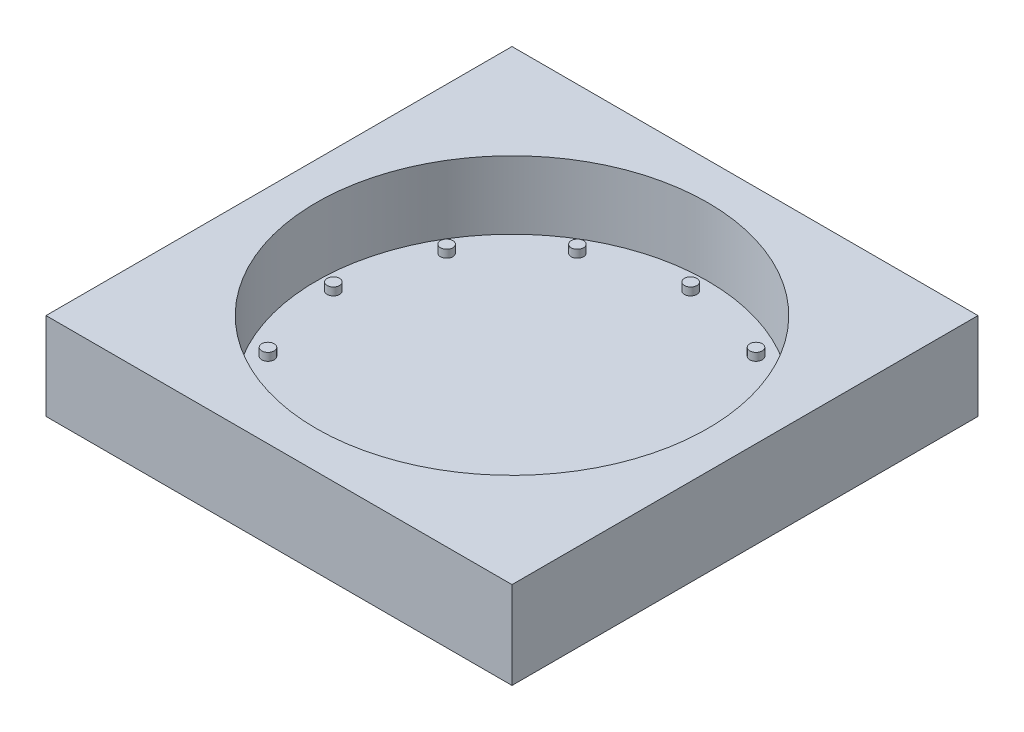
from build123d import *

# Parameters (mm, degrees)
SKETCH1_W           = 152.4
SKETCH1_H           = 152.4
SKETCH1_R           = 64.008
BOSS_EXTRUDE1_DEPTH = 22.225
SKETCH2_W           = 152.4
SKETCH2_H           = 152.4
BOSS_EXTRUDE2_DEPTH = 6.35
SKETCH3_R           = 2.032
BOSS_EXTRUDE3_DEPTH = 2.54
CIRPATTERN1_COUNT   = 12


with BuildPart() as part:
    # Sketch1 → Boss-Extrude1 (new body)
    with BuildSketch(Plane(origin=(0, 0, 0), x_dir=(1, 0, 0), z_dir=(0, 1, 0))):
        Rectangle(SKETCH1_W, SKETCH1_H)
        Circle(SKETCH1_R, mode=Mode.SUBTRACT)
    extrude(amount=BOSS_EXTRUDE1_DEPTH)

    # Sketch2 → Boss-Extrude2 (add)
    with BuildSketch(Plane(origin=(0, 0, 0), x_dir=(-1, 0, 0), z_dir=(0, -1, 0))):
        Rectangle(SKETCH2_W, SKETCH2_H)
    extrude(amount=BOSS_EXTRUDE2_DEPTH)

    # Sketch3 → Boss-Extrude3 (add)
    with BuildSketch(Plane(origin=(0, 0, 0), x_dir=(1, 0, 0), z_dir=(0, 1, 0))):
        with Locations((-58.42, 0)):
            Circle(SKETCH3_R)
    boss_extrude3 = extrude(amount=BOSS_EXTRUDE3_DEPTH)

    # CirPattern1: Boss-Extrude3 ×12 about axis
    cirpattern1_axis = Axis((0, 0, 0), (0, 1, 0))
    for i in range(1, CIRPATTERN1_COUNT):
        add(boss_extrude3.rotate(cirpattern1_axis, i * 360 / CIRPATTERN1_COUNT))


solid = part.part
